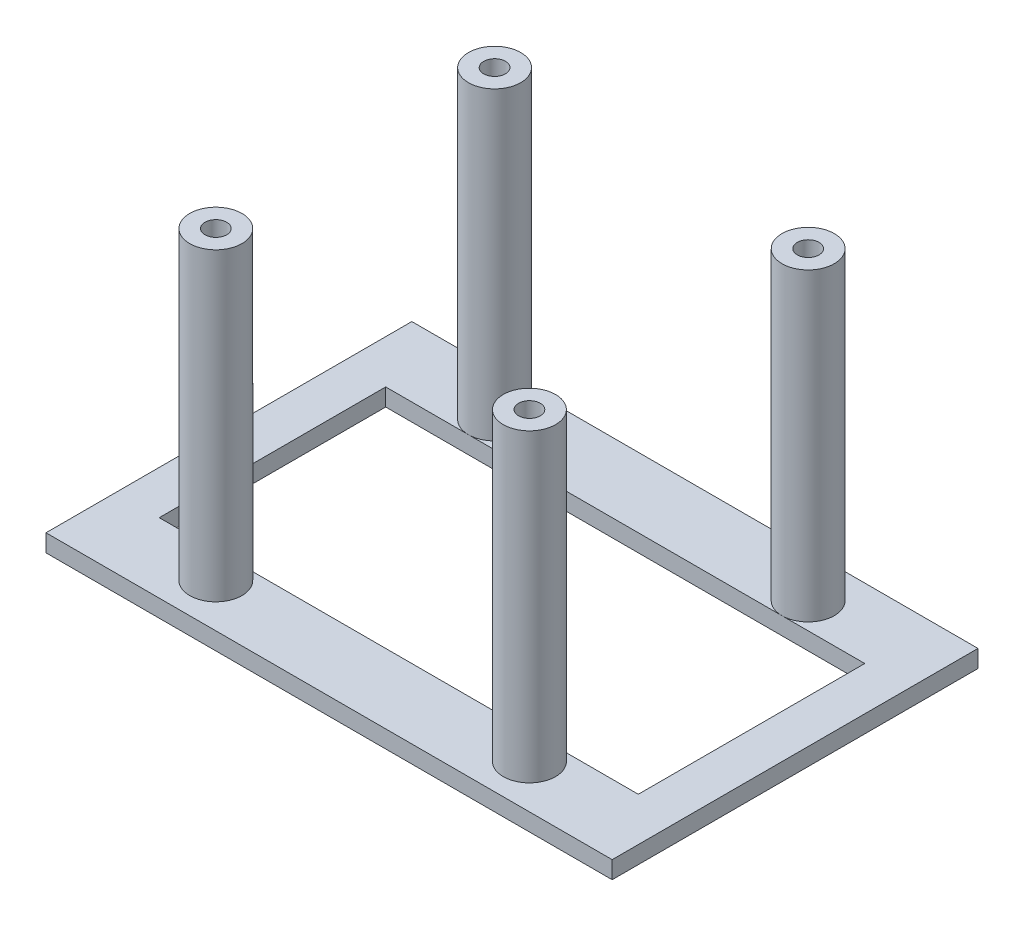
from build123d import *

# Parameters (mm, degrees)
SKETCH1_W           = 65
SKETCH1_H           = 42
SKETCH1_W_2         = 55
SKETCH1_H_2         = 26
BOSS_EXTRUDE2_DEPTH = 2
SKETCH1_3_R         = 3
SKETCH1_3_R_2       = 1.25
BOSS_EXTRUDE3_DEPTH = 35
CUT_EXTRUDE1_START  = 35
SKETCH1_4_R         = 1.25
CUT_EXTRUDE1_DEPTH  = 11


with BuildPart() as part:
    # Sketch1 → Boss-Extrude2 (new body)
    with BuildSketch(Plane(origin=(0, 0, 0), x_dir=(1, 0, 0), z_dir=(0, 1, 0))):
        Rectangle(SKETCH1_W, SKETCH1_H)
        Rectangle(SKETCH1_W_2, SKETCH1_H_2, mode=Mode.SUBTRACT)
    extrude(amount=-BOSS_EXTRUDE2_DEPTH)

    # Sketch1_3 → Boss-Extrude3 (add)
    with BuildSketch(Plane(origin=(0, 0, 0), x_dir=(1, 0, 0), z_dir=(0, 1, 0))):
        with Locations(Location((-18, 16, 0), (0, 0, 270))):
            Circle(SKETCH1_3_R)
        with Locations((-18, 16)):
            Circle(SKETCH1_3_R_2, mode=Mode.SUBTRACT)
        with Locations((-18, 16)):
            Circle(SKETCH1_3_R_2)
        with Locations(Location((18, 16, 0), (0, 0, 270))):
            Circle(SKETCH1_3_R)
        with Locations((18, 16)):
            Circle(SKETCH1_3_R_2, mode=Mode.SUBTRACT)
        with Locations((18, 16)):
            Circle(SKETCH1_3_R_2)
        with Locations(Location((18, -16, 0), (0, 0, 90))):
            Circle(SKETCH1_3_R)
        with Locations((18, -16)):
            Circle(SKETCH1_3_R_2, mode=Mode.SUBTRACT)
        with Locations(Location((-18, -16, 0), (0, 0, 90))):
            Circle(SKETCH1_3_R)
        with Locations((-18, -16)):
            Circle(SKETCH1_3_R_2, mode=Mode.SUBTRACT)
        with Locations((-18, -16)):
            Circle(SKETCH1_3_R_2)
        with Locations((18, -16)):
            Circle(SKETCH1_3_R_2)
    extrude(amount=BOSS_EXTRUDE3_DEPTH)

    # Sketch1_4 → Cut-Extrude1 (cut)
    with BuildSketch(Plane(origin=(0, 0, 0), x_dir=(1, 0, 0), z_dir=(0, 1, 0)).offset(CUT_EXTRUDE1_START)):
        with Locations(Location((-18, 16, 0), (0, 0, 270))):
            Circle(SKETCH1_4_R)
        with Locations(Location((18, 16, 0), (0, 0, 270))):
            Circle(SKETCH1_4_R)
        with Locations(Location((18, -16, 0), (0, 0, 270))):
            Circle(SKETCH1_4_R)
        with Locations(Location((-18, -16, 0), (0, 0, 270))):
            Circle(SKETCH1_4_R)
    extrude(amount=-CUT_EXTRUDE1_DEPTH, mode=Mode.SUBTRACT)


solid = part.part
